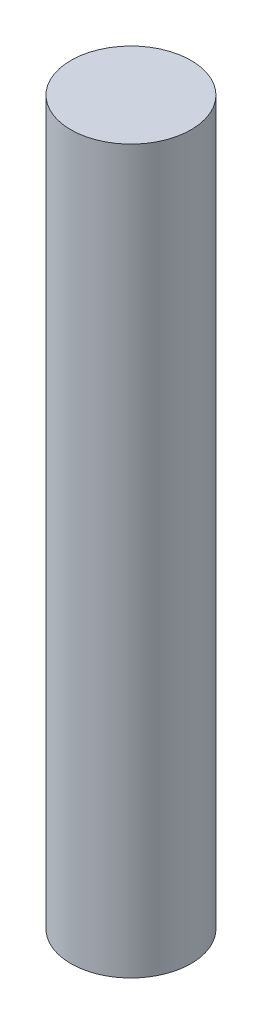
from build123d import *

# Parameters (mm, degrees)
SKETCH1_R           = 6.34
BOSS_EXTRUDE1_DEPTH = 76.17


with BuildPart() as part:
    # Sketch1 → Boss-Extrude1 (new body)
    with BuildSketch(Plane(origin=(0, 0, 0), x_dir=(1, 0, 0), z_dir=(0, 1, 0))):
        Circle(SKETCH1_R)
    extrude(amount=BOSS_EXTRUDE1_DEPTH)


solid = part.part
